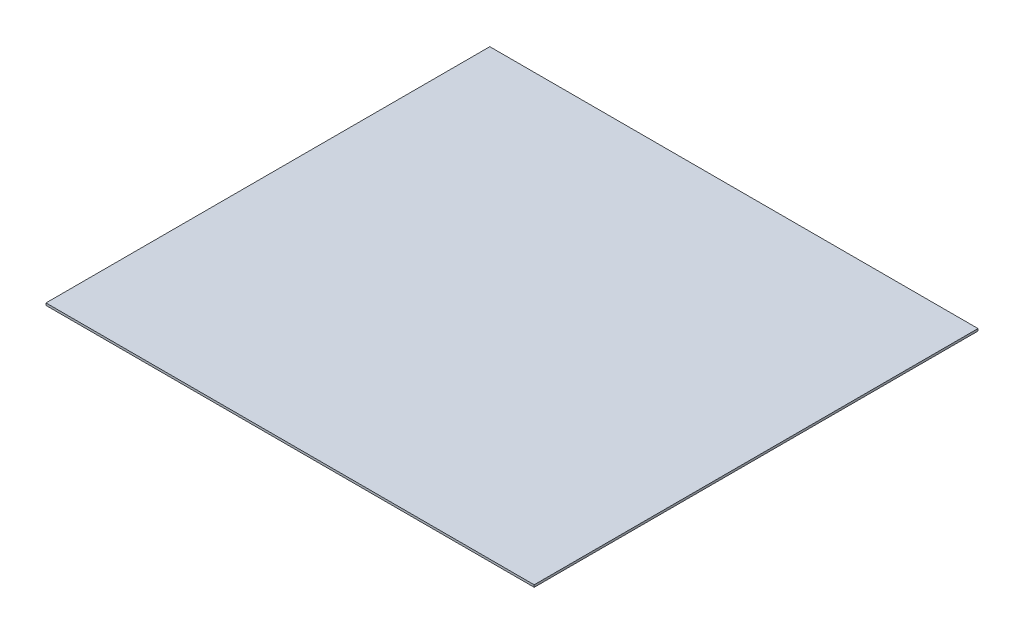
from build123d import *

# Parameters (mm, degrees)
ESQUISSE1_W      = 2200
ESQUISSE1_H      = 2000
EXTRUSION1_DEPTH = 10


with BuildPart() as part:
    # Esquisse1 → Extrusion1 (new body)
    with BuildSketch(Plane(origin=(0, 0, 0), x_dir=(1, 0, 0), z_dir=(0, 1, 0))):
        with Locations((1100, 1000)):
            Rectangle(ESQUISSE1_W, ESQUISSE1_H)
    extrude(amount=EXTRUSION1_DEPTH)


solid = part.part
